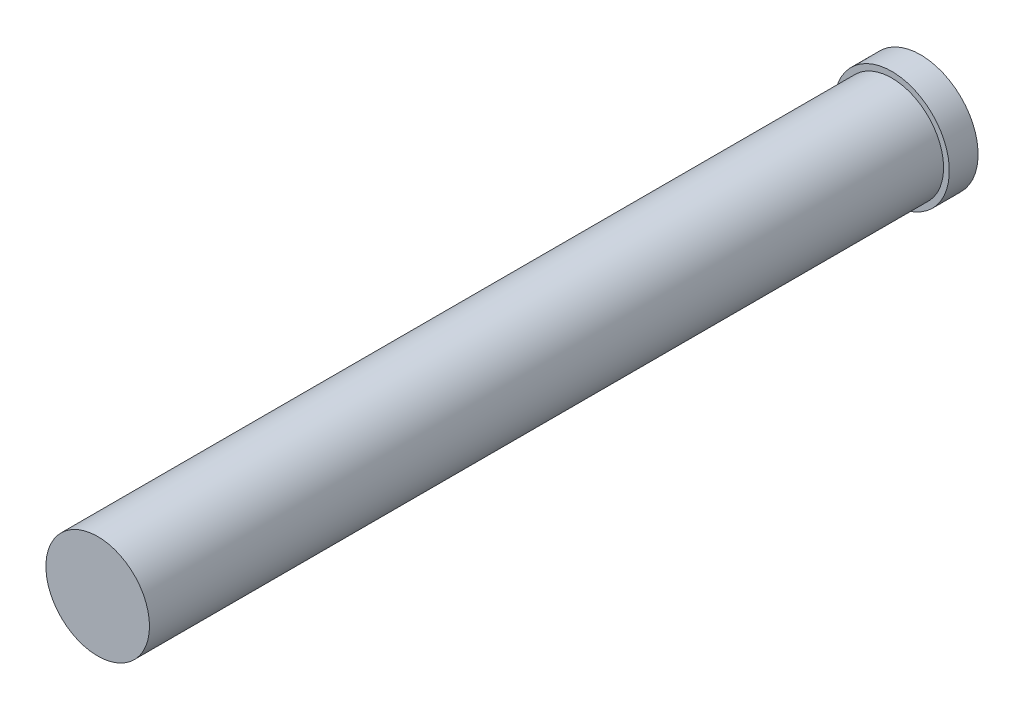
from build123d import *

# Parameters (mm, degrees)
SKETCH1_R           = 2.286
BOSS_EXTRUDE1_DEPTH = 17.526
SKETCH2_R           = 2.54
BOSS_EXTRUDE2_DEPTH = 1.27


with BuildPart() as part:
    # Sketch1 → Boss-Extrude1 (new body, symmetric)
    with BuildSketch(Plane.XY):
        Circle(SKETCH1_R)
    extrude(amount=BOSS_EXTRUDE1_DEPTH, both=True)

    # Sketch2 → Boss-Extrude2 (add)
    with BuildSketch(Plane(origin=(0, 0, -17.526), x_dir=(-1, 0, 0), z_dir=(0, 0, -1))):
        Circle(SKETCH2_R)
    extrude(amount=BOSS_EXTRUDE2_DEPTH)


solid = part.part
